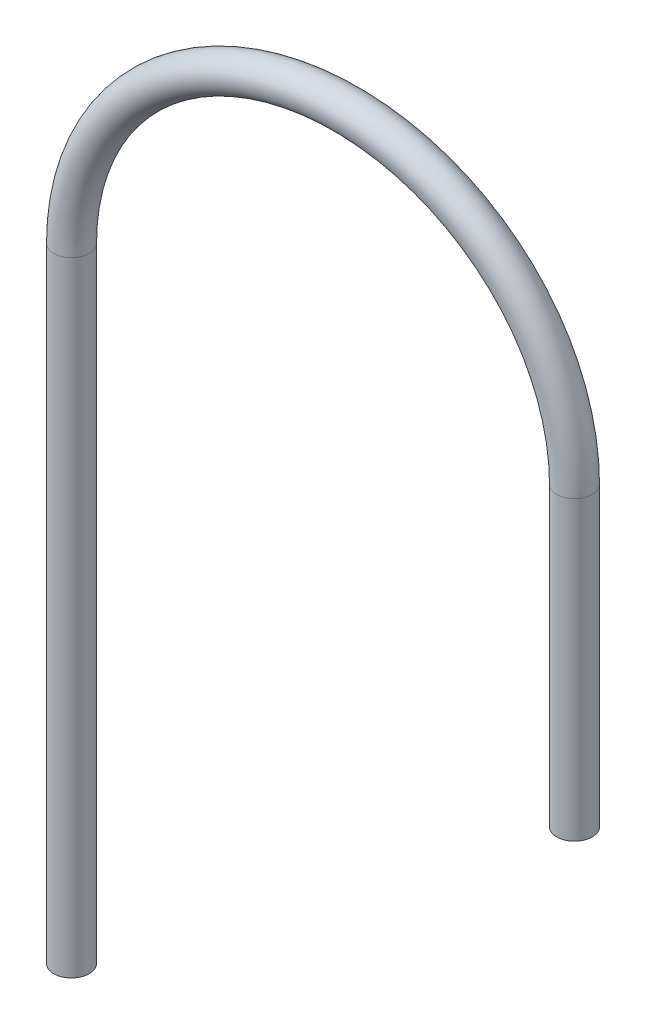
from build123d import *

# Parameters (mm, degrees)
BALAYAGE_MINCE1_PROFILE_R   = 3
BALAYAGE_MINCE1_PROFILE_R_2 = 2


with BuildPart() as part:
    # Balayage-Mince1: sweep along a curve in space
    with BuildLine() as balayage_mince1_path:
        Line((42, 165, -59.25), (42, 215.275, -59.25))
        ThreePointArc((42, 215.275, -59.25), (3, 254.443107243, -55.625), (-36, 215.275, -52))
        Line((-36, 215.275, -52), (-36, 109.55, -52))
    # Balayage-Mince1 profile (on start of the path) → Balayage-Mince1 (sweep)
    with BuildSketch(Plane(origin=(42, 165, -59.25), x_dir=(0, 0, 1), z_dir=(0, 1, 0))):
        Circle(BALAYAGE_MINCE1_PROFILE_R)
        Circle(BALAYAGE_MINCE1_PROFILE_R_2, mode=Mode.SUBTRACT)
    sweep(path=balayage_mince1_path.line)


solid = part.part
